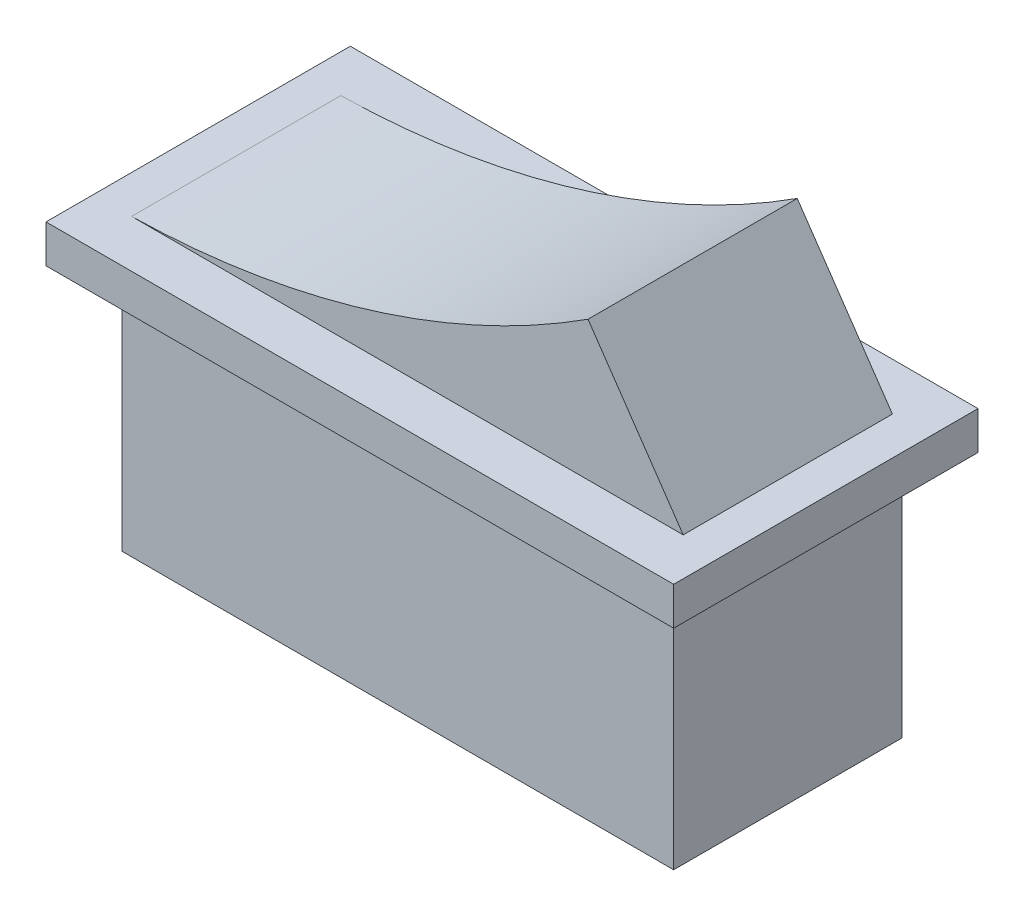
from build123d import *

# Parameters (mm, degrees)
SKETCH_1_W      = 33
SKETCH_1_H      = 16
EXTRUDE_1_DEPTH = 2
EXTRUDE_2_DEPTH = 5.5
SKETCH_3_W      = 29
SKETCH_3_H      = 12
EXTRUDE_3_DEPTH = 13


with BuildPart() as part:
    # 草图1 → 凸台-拉伸1 (new body)
    with BuildSketch(Plane(origin=(0, 0, 0), x_dir=(1, 0, 0), z_dir=(0, 1, 0))):
        Rectangle(SKETCH_1_W, SKETCH_1_H)
    extrude(amount=EXTRUDE_1_DEPTH)

    # 草图2 → 凸台-拉伸2 (add, symmetric)
    with BuildSketch(Plane.XY):
        with BuildLine():
            ThreePointArc((-14.5, 2), (-1.99286503, 3.990553371), (9.496887626, 9.317495439))
            Line((9.496887626, 9.317495439), (14.5, 2))
            Line((14.5, 2), (-14.5, 2))
        make_face()
    extrude(amount=EXTRUDE_2_DEPTH, both=True)

    # 草图3 → 凸台-拉伸3 (add)
    with BuildSketch(Plane(origin=(0, 0, 0), x_dir=(1, 0, 0), z_dir=(0, 1, 0))):
        Rectangle(SKETCH_3_W, SKETCH_3_H)
    extrude(amount=-EXTRUDE_3_DEPTH)


solid = part.part
